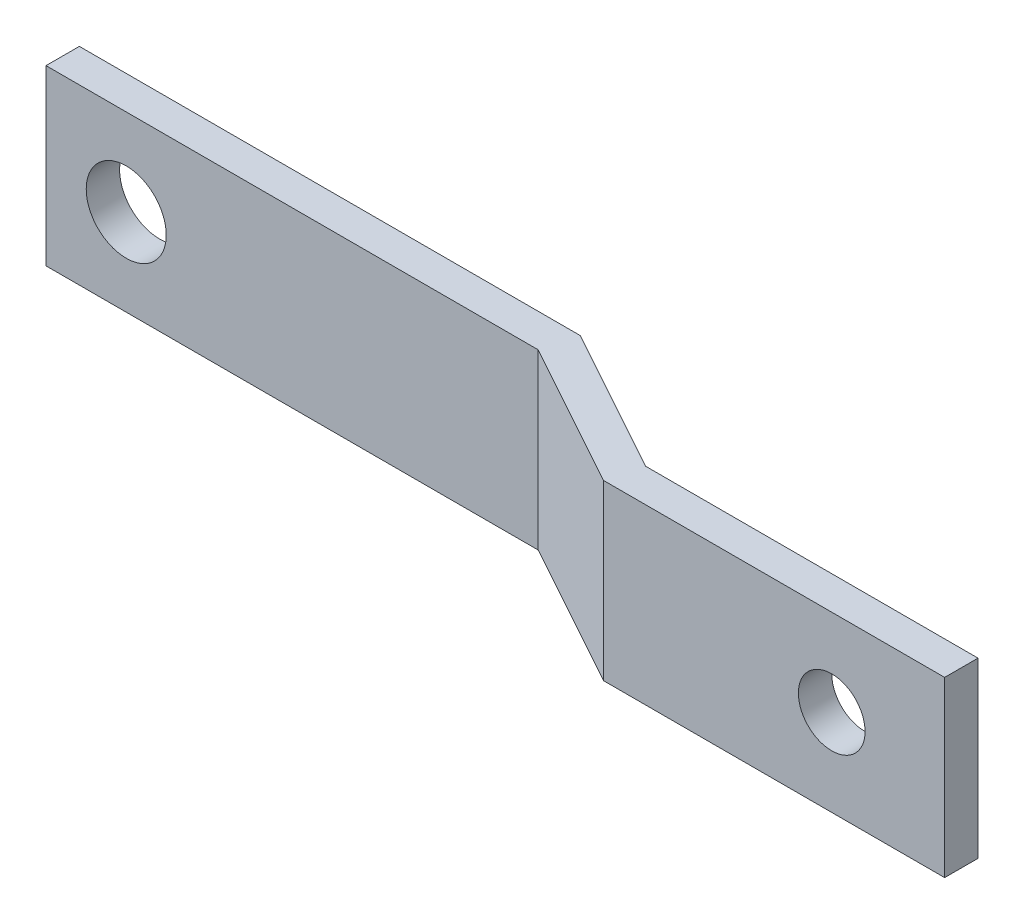
from build123d import *

# Parameters (mm, degrees)
EXTRUDE_THIN1_DEPTH = 13.208
CUT_EXTRUDE1_REACH  = 10.669
SKETCH3_R           = 3.048
CUT_EXTRUDE2_REACH  = 10.669
SKETCH4_R           = 2.54


with BuildPart() as part:
    # Sketch1 → Extrude-Thin1 (new body)
    with BuildSketch(Plane(origin=(0, 0, 0), x_dir=(1, 0, 0), z_dir=(0, 1, 0))):
        Polygon((0, 0), (38.139058105, 0), (49.245270394, -6.128868698), (74.567434413, -6.128868698), (74.567434413, -8.668868698), (48.590941352, -8.668868698), (37.484729063, -2.54), (0, -2.54), align=None)
    extrude(amount=EXTRUDE_THIN1_DEPTH)

    # Sketch3 → Cut-Extrude1 (cut, up to next)
    with BuildSketch(Plane(origin=(0, 0, 0), x_dir=(-1, 0, 0), z_dir=(0, 0, -1)), mode=Mode.PRIVATE) as cut_extrude1_sk1:
        with Locations((-6.110625798, 6.604)):
            Circle(SKETCH3_R)
    cut_extrude1_tool1 = extrude(cut_extrude1_sk1.sketch, amount=-CUT_EXTRUDE1_REACH, mode=Mode.PRIVATE) & part.part
    add(cut_extrude1_tool1.solids().sort_by_distance((6.110626, 6.604, 0))[0], mode=Mode.SUBTRACT)

    # Sketch4 → Cut-Extrude2 (cut, up to next)
    with BuildSketch(Plane.XY.offset(8.668868698), mode=Mode.PRIVATE) as cut_extrude2_sk1:
        with Locations((65.966386127, 6.604)):
            Circle(SKETCH4_R)
    cut_extrude2_tool1 = extrude(cut_extrude2_sk1.sketch, amount=-CUT_EXTRUDE2_REACH, mode=Mode.PRIVATE) & part.part
    add(cut_extrude2_tool1.solids().sort_by_distance((65.966386, 6.604, 8.668869))[0], mode=Mode.SUBTRACT)


solid = part.part
